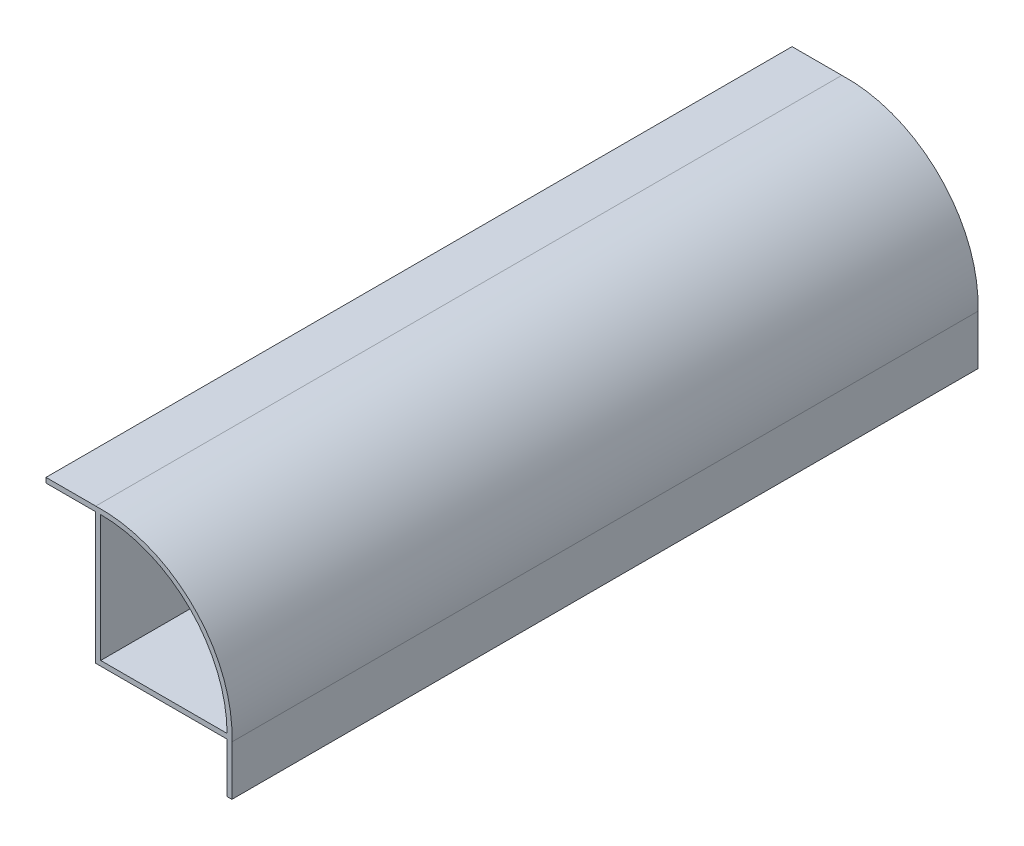
from build123d import *

# Parameters (mm, degrees)
CROQUIS1_W              = 10
CROQUIS1_H              = 1
CROQUIS1_W_2            = 1
CROQUIS1_H_2            = 10
SALIENTE_EXTRUIR1_DEPTH = 75


with BuildPart() as part:
    # Croquis1 → Saliente-Extruir1 (new body, symmetric)
    with BuildSketch(Plane.XY):
        with BuildLine():
            ThreePointArc((-13.7, 13.681053808), (5.967619023, 5.967619023), (13.681053808, -13.7))
            Line((13.681053808, -13.7), (-13.7, -13.7))
            Line((-13.7, -13.7), (-13.7, 13.681053808))
        make_face()
        with BuildLine():
            Line((-12.7, -12.7), (-12.7, 12.7))
            ThreePointArc((-12.7, 12.7), (5.260512242, 5.260512242), (12.7, -12.7))
            Line((12.7, -12.7), (-12.7, -12.7))
        make_face(mode=Mode.SUBTRACT)
        with Locations((-18.7, 13.181053808)):
            Rectangle(CROQUIS1_W, CROQUIS1_H)
        with Locations((13.181053808, -18.7)):
            Rectangle(CROQUIS1_W_2, CROQUIS1_H_2)
    extrude(amount=SALIENTE_EXTRUIR1_DEPTH, both=True)


solid = part.part
